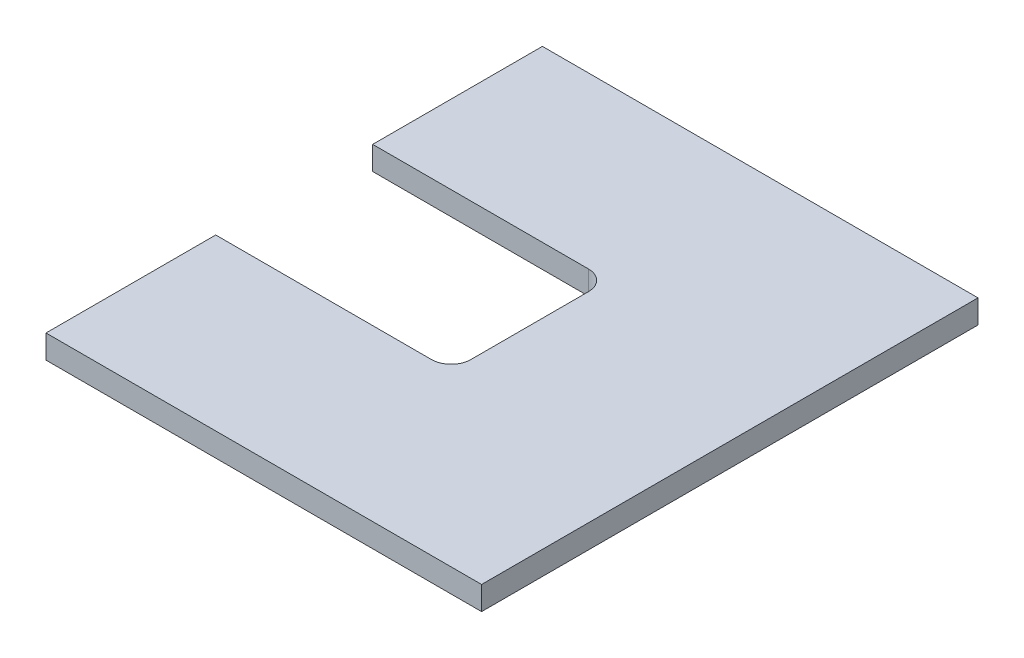
from build123d import *

# Parameters (mm, degrees)
SKETCH1_W           = 111
SKETCH1_H           = 126.5
BOSS_EXTRUDE1_DEPTH = 6
SKETCH2_W           = 60
SKETCH2_H           = 40
CUT_EXTRUDE1_DEPTH  = 7
FILLET1_R           = 5


with BuildPart() as part:
    # Sketch1 → Boss-Extrude1 (new body)
    with BuildSketch(Plane(origin=(0, 0, 0), x_dir=(1, 0, 0), z_dir=(0, 1, 0))):
        with Locations((55.5, 63.25)):
            Rectangle(SKETCH1_W, SKETCH1_H)
    extrude(amount=BOSS_EXTRUDE1_DEPTH)

    # Sketch2 → Cut-Extrude1 (cut, through all)
    with BuildSketch(Plane(origin=(0, 6, 0), x_dir=(1, 0, 0), z_dir=(0, 1, 0))):
        with Locations((30, 63.25)):
            Rectangle(SKETCH2_W, SKETCH2_H)
    extrude(amount=-CUT_EXTRUDE1_DEPTH, mode=Mode.SUBTRACT)

    # Fillet1
    fillet1_edges = [part.edges().sort_by_distance(p)[0] for p in [
        (60, 3, -83.25),
        (60, 3, -43.25),
    ]]
    fillet(fillet1_edges, radius=FILLET1_R)


solid = part.part
